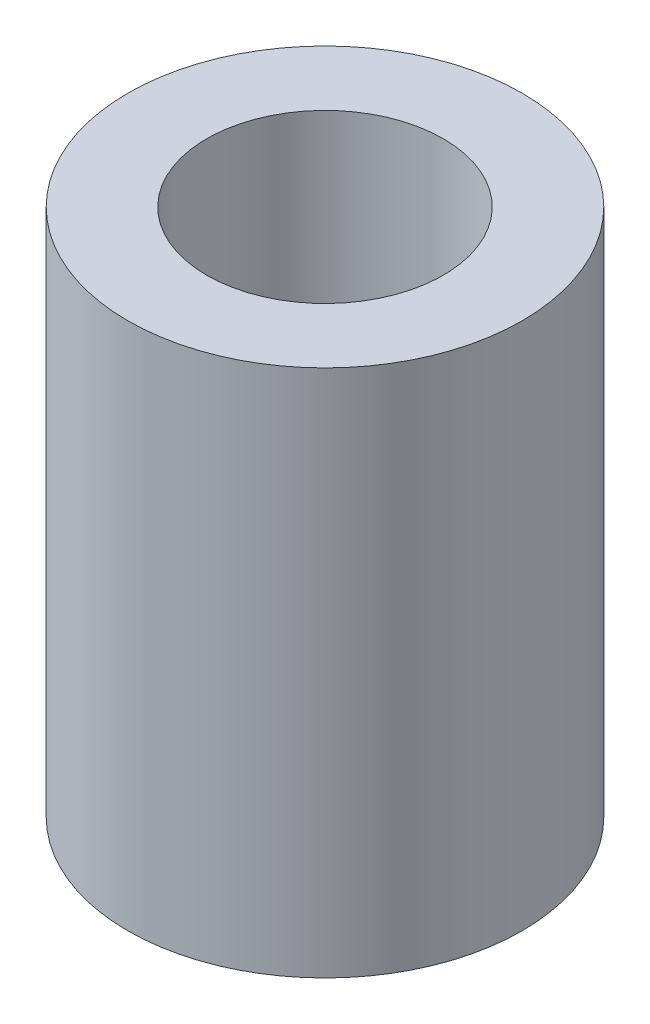
from build123d import *

# Parameters (mm, degrees)
SKETCH1_R           = 2.5
SKETCH1_R_2         = 1.5
BOSS_EXTRUDE1_DEPTH = 6.7


with BuildPart() as part:
    # Sketch1 → Boss-Extrude1 (new body)
    with BuildSketch(Plane(origin=(0, 0, 0), x_dir=(1, 0, 0), z_dir=(0, 1, 0))):
        Circle(SKETCH1_R)
        Circle(SKETCH1_R_2, mode=Mode.SUBTRACT)
    extrude(amount=BOSS_EXTRUDE1_DEPTH)


solid = part.part
